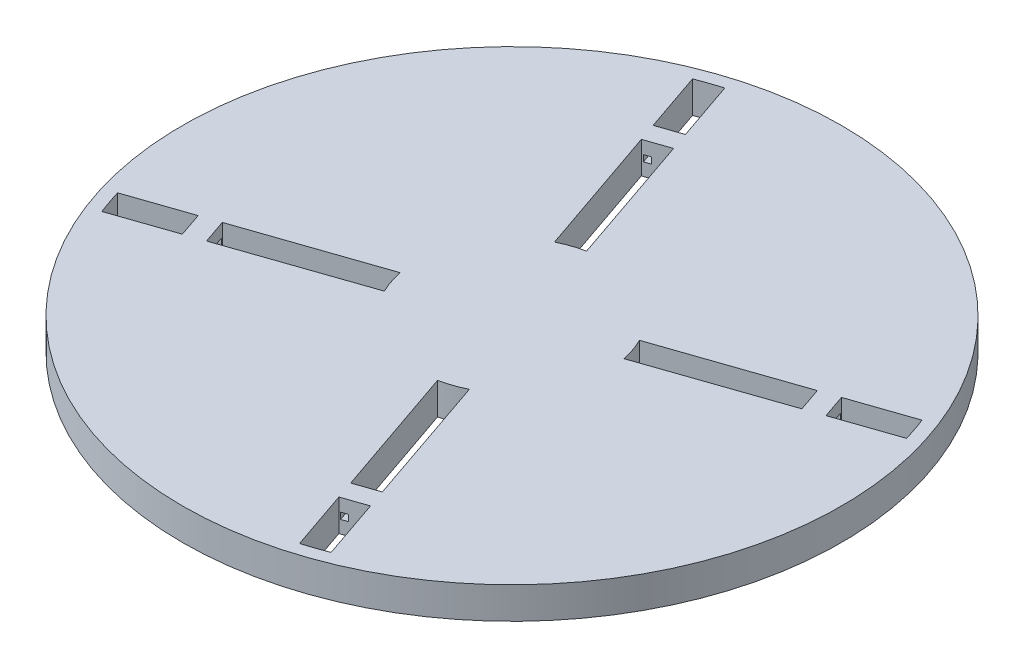
from build123d import *

# Parameters (mm, degrees)
SKETCH1_R           = 52
BOSS_EXTRUDE1_DEPTH = 5
CUT_EXTRUDE3_DEPTH  = 2.4
CUT_EXTRUDE6_DEPTH  = 5
CUT_EXTRUDE7_DEPTH  = 5
CIRPATTERN1_COUNT   = 4


with BuildPart() as part:
    # Sketch1 → Boss-Extrude1 (new body)
    with BuildSketch(Plane(origin=(0, 0, 0), x_dir=(1, 0, 0), z_dir=(0, 1, 0))):
        Circle(SKETCH1_R)
    extrude(amount=BOSS_EXTRUDE1_DEPTH)

    # Sketch4 → Cut-Extrude3 (cut)
    with BuildSketch(Plane.XZ):
        Polygon((-30.27517129, 23.328400706), (-34.046075388, 26.612474905), (-32.609483493, 28.262026633), (-31.859987156, 27.61559837), (-30.422563818, 29.274773748), (-24.360613821, 24.023015245), (-26.001788353, 22.128655871), (-26.755565092, 22.781688872), (-27.999168756, 21.346233829), align=None)
        Polygon((-37.903449254, -4.912108587), (-42.892072249, -5.256349311), (-43.042657591, -3.074116227), (-42.05558984, -3.001236093), (-42.212392211, -0.811610142), (-34.212392211, -0.238718243), (-34.033363493, -2.738718243), (-35.028128199, -2.809954823), (-34.892468788, -4.704335401), align=None)
        Polygon((-4.912108587, 37.903449254), (-5.256349311, 42.892072249), (-3.074116227, 43.042657591), (-3.001236093, 42.05558984), (-0.811610142, 42.212392211), (-0.238718243, 34.212392211), (-2.738718243, 34.033363493), (-2.809954823, 35.028128199), (-4.704335401, 34.892468788), align=None)
        Polygon((23.328400706, 30.27517129), (26.612474905, 34.046075388), (28.262026633, 32.609483493), (27.61559837, 31.859987156), (29.274773748, 30.422563818), (24.023015245, 24.360613821), (22.128655871, 26.001788353), (22.781688872, 26.755565092), (21.346233829, 27.999168756), align=None)
        Polygon((37.903449254, 4.912108587), (42.892072249, 5.256349311), (43.042657591, 3.074116227), (42.05558984, 3.001236093), (42.212392211, 0.811610142), (34.212392211, 0.238718243), (34.033363493, 2.738718243), (35.028128199, 2.809954823), (34.892468788, 4.704335401), align=None)
        Polygon((30.27517129, -23.328400706), (34.046075388, -26.612474905), (32.609483493, -28.262026633), (31.859987156, -27.61559837), (30.422563818, -29.274773748), (24.360613821, -24.023015245), (26.001788353, -22.128655871), (26.755565092, -22.781688872), (27.999168756, -21.346233829), align=None)
        Polygon((4.912108587, -37.903449254), (5.256349311, -42.892072249), (3.074116227, -43.042657591), (3.001236093, -42.05558984), (0.811610142, -42.212392211), (0.238718243, -34.212392211), (2.738718243, -34.033363493), (2.809954823, -35.028128199), (4.704335401, -34.892468788), align=None)
        Polygon((-23.328400706, -30.27517129), (-26.612474905, -34.046075388), (-28.262026633, -32.609483493), (-27.61559837, -31.859987156), (-29.274773748, -30.422563818), (-24.023015245, -24.360613821), (-22.128655871, -26.001788353), (-22.781688872, -26.755565092), (-21.346233829, -27.999168756), align=None)
    extrude(amount=-CUT_EXTRUDE3_DEPTH, mode=Mode.SUBTRACT)

    # Sketch8 → Cut-Extrude6 (cut)
    with BuildSketch(Plane.XZ):
        with BuildLine():
            Line((-47.90528304, 14.320749174), (-38.443448295, 11.078076484))
            Line((-38.443448295, 11.078076484), (-37.143919852, 14.869986599))
            Line((-37.143919852, 14.869986599), (-46.600463643, 18.121721449))
            ThreePointArc((-46.600463643, 18.121721449), (-47.291076183, 16.2343498), (-47.90528304, 14.320749174))
        make_face()
        with BuildLine():
            Line((2.958916284, 14.705264854), (10.141430922, 35.593119285))
            Line((10.141430922, 35.593119285), (13.857171973, 34.31542154))
            Line((13.857171973, 34.31542154), (6.696805901, 13.422100831))
            ThreePointArc((6.696805901, 13.422100831), (4.87030494, 14.187322855), (2.958916284, 14.705264854))
        make_face()
        with BuildLine():
            Line((13.422100831, -6.696805901), (34.31542154, -13.857171973))
            Line((34.31542154, -13.857171973), (35.593119285, -10.141430922))
            Line((35.593119285, -10.141430922), (14.705264854, -2.958916284))
            ThreePointArc((14.705264854, -2.958916284), (14.187322855, -4.87030494), (13.422100831, -6.696805901))
        make_face()
        with BuildLine():
            Line((-13.893125689, -34.303058466), (-6.710611051, -13.415204036))
            ThreePointArc((-6.710611051, -13.415204036), (-4.87030494, -14.187322855), (-2.943785902, -14.708301213))
            Line((-2.943785902, -14.708301213), (-10.10547522, -35.605483041))
            Line((-10.10547522, -35.605483041), (-13.893125689, -34.303058466))
        make_face()
        with BuildLine():
            Line((-14.320749174, -47.90528304), (-11.078076484, -38.443448295))
            Line((-11.078076484, -38.443448295), (-14.869986599, -37.143919852))
            Line((-14.869986599, -37.143919852), (-18.121721449, -46.600463643))
            ThreePointArc((-18.121721449, -46.600463643), (-16.2343498, -47.291076183), (-14.320749174, -47.90528304))
        make_face()
        with BuildLine():
            Line((-35.605483041, 10.10547522), (-34.303058466, 13.893125689))
            Line((-34.303058466, 13.893125689), (-13.415204036, 6.710611051))
            ThreePointArc((-13.415204036, 6.710611051), (-14.187322855, 4.87030494), (-14.708301213, 2.943785902))
            Line((-14.708301213, 2.943785902), (-35.605483041, 10.10547522))
        make_face()
        with BuildLine():
            Line((11.116964613, 38.430120915), (14.831096483, 37.157247914))
            Line((14.831096483, 37.157247914), (18.073769174, 46.619082658))
            ThreePointArc((18.073769174, 46.619082658), (16.2343498, 47.291076183), (14.370026682, 47.890524461))
            Line((14.370026682, 47.890524461), (11.116964613, 38.430120915))
        make_face()
        with BuildLine():
            Line((38.430120915, -11.116964613), (37.157247914, -14.831096483))
            Line((37.157247914, -14.831096483), (46.619082658, -18.073769174))
            ThreePointArc((46.619082658, -18.073769174), (47.291076183, -16.2343498), (47.890524461, -14.370026682))
            Line((47.890524461, -14.370026682), (38.430120915, -11.116964613))
        make_face()
    extrude(amount=-CUT_EXTRUDE6_DEPTH, mode=Mode.SUBTRACT)

    # Sketch9 → Cut-Extrude7 (cut)
    with BuildSketch(Plane(origin=(34.948088876, 0, -12.017278305), x_dir=(0.325173485, 0, 0.945654379), z_dir=(-0.945654379, 0, 0.325173485))):
        Polygon((0.769009966, 2.5), (0.769009966, 2), (1.769009966, 2), (1.769009966, 3), (0.769009966, 3), align=None)
        Polygon((-0.730990034, 2.5), (-0.730990034, 2), (-1.730990034, 2), (-1.730990034, 3), (-0.730990034, 3), align=None)
    cut_extrude7 = extrude(amount=-CUT_EXTRUDE7_DEPTH, mode=Mode.SUBTRACT)

    # CirPattern1: Cut-Extrude7 ×4 about axis
    cirpattern1_axis = Axis((0, 0, 0), (0, 1, 0))
    for i in range(1, CIRPATTERN1_COUNT):
        add(cut_extrude7.rotate(cirpattern1_axis, i * 360 / CIRPATTERN1_COUNT), mode=Mode.SUBTRACT)


solid = part.part
